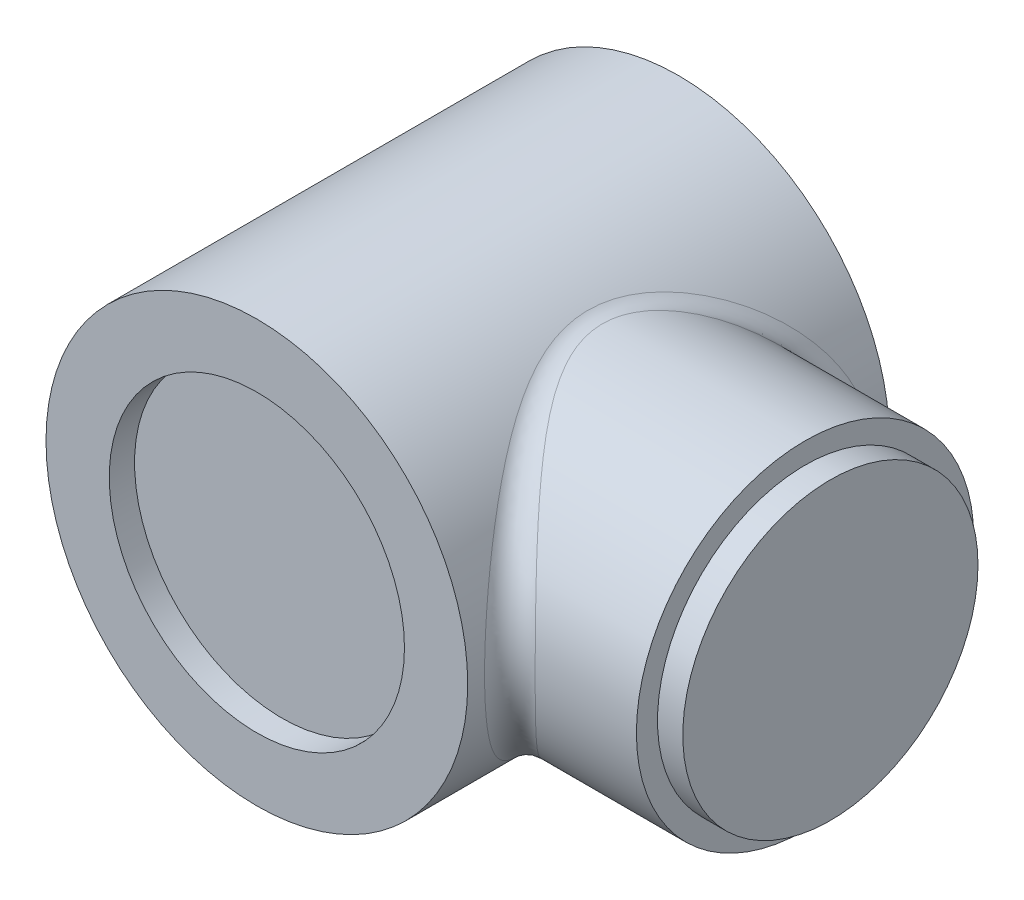
from build123d import *

# Parameters (mm, degrees)
SKETCH1_R           = 25
BOSS_EXTRUDE1_DEPTH = 25
SKETCH2_R           = 17.5
CUT_EXTRUDE1_DEPTH  = 3
SKETCH3_R           = 20
BOSS_EXTRUDE2_DEPTH = 40
SKETCH4_R           = 17.5
BOSS_EXTRUDE3_DEPTH = 3
FILLET1_R           = 3


with BuildPart() as part:
    # Sketch1 → Boss-Extrude1 (new body, symmetric)
    with BuildSketch(Plane.XY):
        Circle(SKETCH1_R)
    extrude(amount=BOSS_EXTRUDE1_DEPTH, both=True)

    # Sketch2 → Cut-Extrude1 (cut)
    with BuildSketch(Plane.XY.offset(25)):
        Circle(SKETCH2_R)
    cut_extrude1 = extrude(amount=-CUT_EXTRUDE1_DEPTH, mode=Mode.SUBTRACT)

    # Mirror1: Cut-Extrude1 across plane
    add(cut_extrude1.mirror(Plane.XY), mode=Mode.SUBTRACT)

    # Sketch3 → Boss-Extrude2 (add)
    with BuildSketch(Plane(origin=(0, 0, 0), x_dir=(0, 0, -1), z_dir=(1, 0, 0))):
        Circle(SKETCH3_R)
    extrude(amount=BOSS_EXTRUDE2_DEPTH)

    # Sketch4 → Boss-Extrude3 (add)
    with BuildSketch(Plane(origin=(40, 0, 0), x_dir=(0, 0, -1), z_dir=(1, 0, 0))):
        Circle(SKETCH4_R)
    extrude(amount=BOSS_EXTRUDE3_DEPTH)

    # Fillet1
    fillet1_edges = [part.edges().sort_by_distance(p)[0] for p in [
        (15, 20, 0),
    ]]
    fillet(fillet1_edges, radius=FILLET1_R)


solid = part.part
